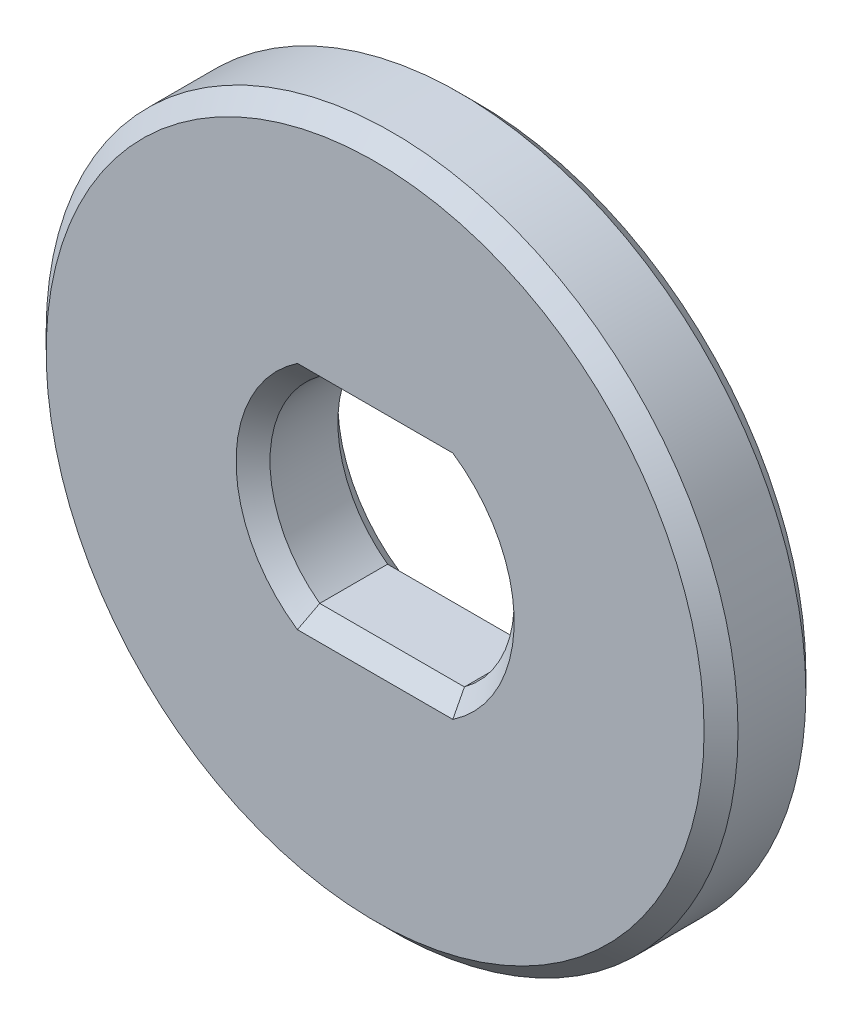
from build123d import *

# Parameters (mm, degrees)
SKETCH1_R           = 10.2
BOSS_EXTRUDE1_DEPTH = 3
CHAMFER1_SIZE       = 0.5


with BuildPart() as part:
    # Sketch1 → Boss-Extrude1 (new body)
    with BuildSketch(Plane.XY):
        Circle(SKETCH1_R)
        with BuildLine():
            Line((-2.133072901, 2.9), (2.133072901, 2.9))
            ThreePointArc((2.133072901, 2.9), (3.6, 0), (2.133072901, -2.9))
            Line((2.133072901, -2.9), (-2.133072901, -2.9))
            ThreePointArc((-2.133072901, -2.9), (-3.6, 0), (-2.133072901, 2.9))
        make_face(mode=Mode.SUBTRACT)
    extrude(amount=BOSS_EXTRUDE1_DEPTH)

    # Chamfer1
    chamfer1_edges = [part.edges().sort_by_distance(p)[0] for p in [
        (3.6, 0, 3),
        (0, 2.9, 3),
        (-10.2, 0, 0),
        (-10.2, 0, 3),
        (-3.6, 0, 0),
        (0, -2.9, 0),
        (3.6, 0, 0),
        (0, 2.9, 0),
        (-3.6, 0, 3),
        (0, -2.9, 3),
    ]]
    chamfer(chamfer1_edges, length=CHAMFER1_SIZE)


solid = part.part
